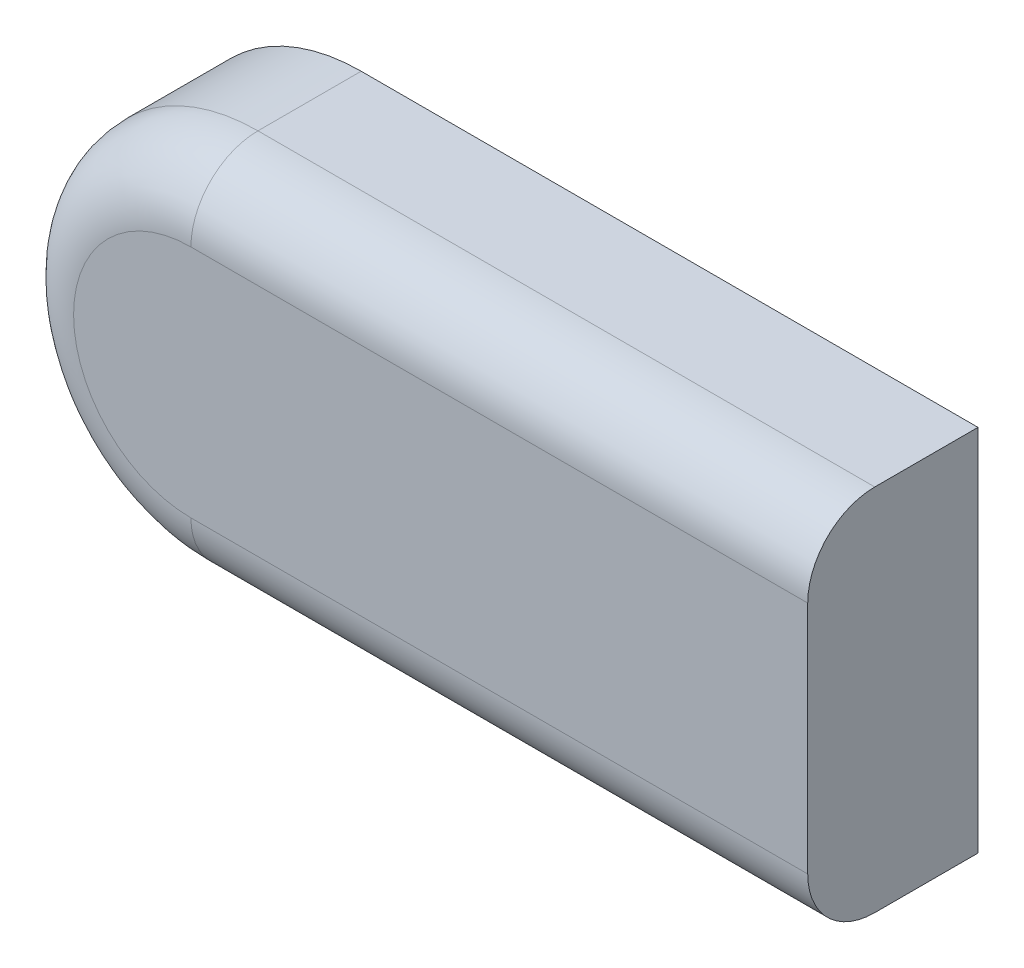
from build123d import *

# Parameters (mm, degrees)
BOSS_EXTRUDE3_DEPTH = 25.4
BOSS_EXTRUDE4_DEPTH = 4
FILLET2_R           = 10


with BuildPart() as part:
    # Sketch4 → Boss-Extrude3 (new body)
    with BuildSketch(Plane.XY):
        with BuildLine():
            Line((79.118213734, 41.276110426), (-12.893671351, 41.276110426))
            ThreePointArc((-12.893671351, 41.276110426), (-40.393671351, 13.776110426), (-12.893671351, -13.723889574))
            Line((-12.893671351, -13.723889574), (79.118213734, -13.723889574))
            Line((79.118213734, -13.723889574), (79.118213734, 41.276110426))
        make_face()
        with BuildLine():
            Line((-12.472737934, 38.276110426), (76.118213734, 38.276110426))
            Line((76.118213734, 38.276110426), (76.118213734, -10.723889574))
            Line((76.118213734, -10.723889574), (-12.472737934, -10.723889574))
            ThreePointArc((-12.472737934, -10.723889574), (-36.972737934, 13.776110426), (-12.472737934, 38.276110426))
        make_face(mode=Mode.SUBTRACT)
    extrude(amount=BOSS_EXTRUDE3_DEPTH)

    # Sketch6 → Boss-Extrude4 (add)
    with BuildSketch(Plane.XY.offset(25.4)):
        with BuildLine():
            Line((-12.893671351, 41.276110426), (79.118213734, 41.276110426))
            Line((79.118213734, 41.276110426), (79.118213734, -13.723889574))
            Line((79.118213734, -13.723889574), (-12.893671351, -13.723889574))
            ThreePointArc((-12.893671351, -13.723889574), (-40.393671351, 13.776110426), (-12.893671351, 41.276110426))
        make_face()
    extrude(amount=-BOSS_EXTRUDE4_DEPTH)

    # Fillet2
    fillet2_edges = [part.edges().sort_by_distance(p)[0] for p in [
        (-40.393671351, 13.776110426, 25.4),
        (33.112271192, -13.723889574, 25.4),
        (33.112271192, 41.276110426, 25.4),
    ]]
    fillet(fillet2_edges, radius=FILLET2_R)


solid = part.part
